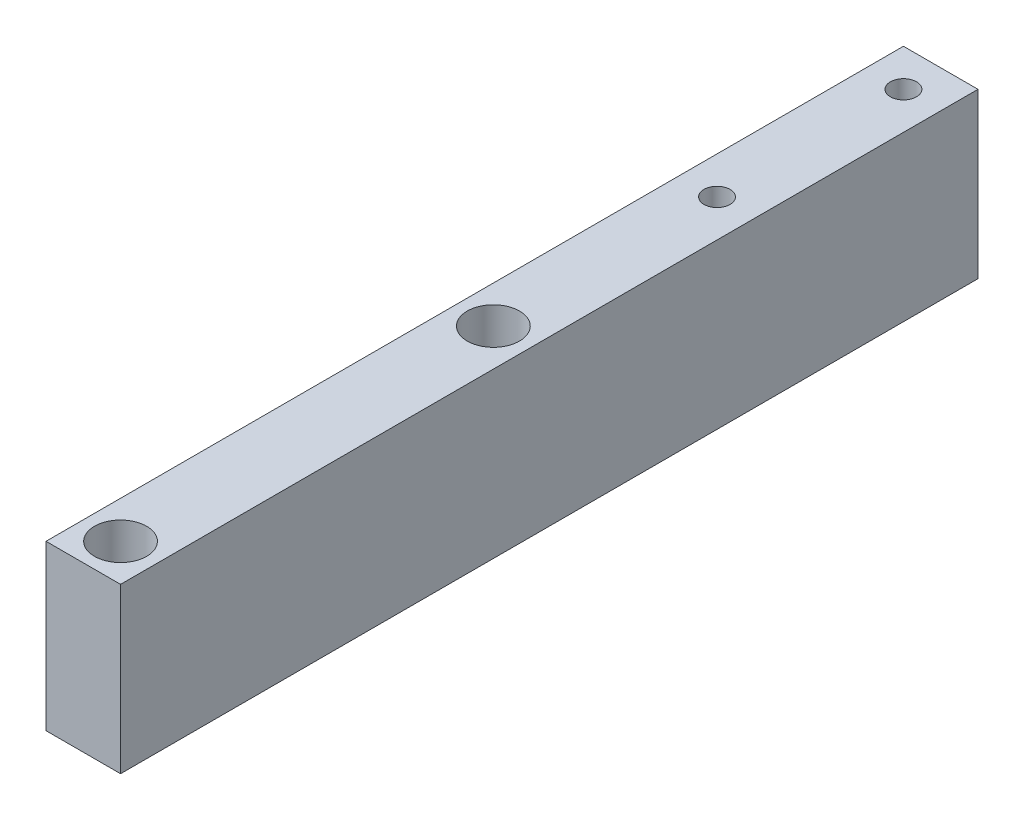
from build123d import *

# Parameters (mm, degrees)
SKETCH1_W           = 10
SKETCH1_H           = 115
BOSS_EXTRUDE1_DEPTH = 22
SKETCH3_R           = 2.05
CUT_EXTRUDE1_DEPTH  = 22
SKETCH4_R           = 3.5
CUT_EXTRUDE2_DEPTH  = 12
SKETCH7_R           = 1.75
CUT_EXTRUDE3_DEPTH  = 23


with BuildPart() as part:
    # Sketch1 → Boss-Extrude1 (new body)
    with BuildSketch(Plane(origin=(0, 0, 0), x_dir=(1, 0, 0), z_dir=(0, 1, 0))):
        Rectangle(SKETCH1_W, SKETCH1_H)
    extrude(amount=BOSS_EXTRUDE1_DEPTH)

    # Sketch3 → Cut-Extrude1 (cut)
    with BuildSketch(Plane(origin=(0, 22, 0), x_dir=(1, 0, 0), z_dir=(0, 1, 0))):
        with Locations((0, -52.5)):
            Circle(SKETCH3_R)
        with Locations((0, -2.5)):
            Circle(SKETCH3_R)
    extrude(amount=-CUT_EXTRUDE1_DEPTH, mode=Mode.SUBTRACT)

    # Sketch4 → Cut-Extrude2 (cut)
    with BuildSketch(Plane(origin=(0, 22, 0), x_dir=(1, 0, 0), z_dir=(0, 1, 0))):
        with Locations((0, -52.5)):
            Circle(SKETCH4_R)
        with Locations((0, -2.5)):
            Circle(SKETCH4_R)
    extrude(amount=-CUT_EXTRUDE2_DEPTH, mode=Mode.SUBTRACT)

    # Sketch7 → Cut-Extrude3 (cut, through all)
    with BuildSketch(Plane(origin=(0, 22, 0), x_dir=(1, 0, 0), z_dir=(0, 1, 0))):
        with Locations((0, 52.5)):
            Circle(SKETCH7_R)
        with Locations((0, 27.5)):
            Circle(SKETCH7_R)
    extrude(amount=-CUT_EXTRUDE3_DEPTH, mode=Mode.SUBTRACT)


solid = part.part
